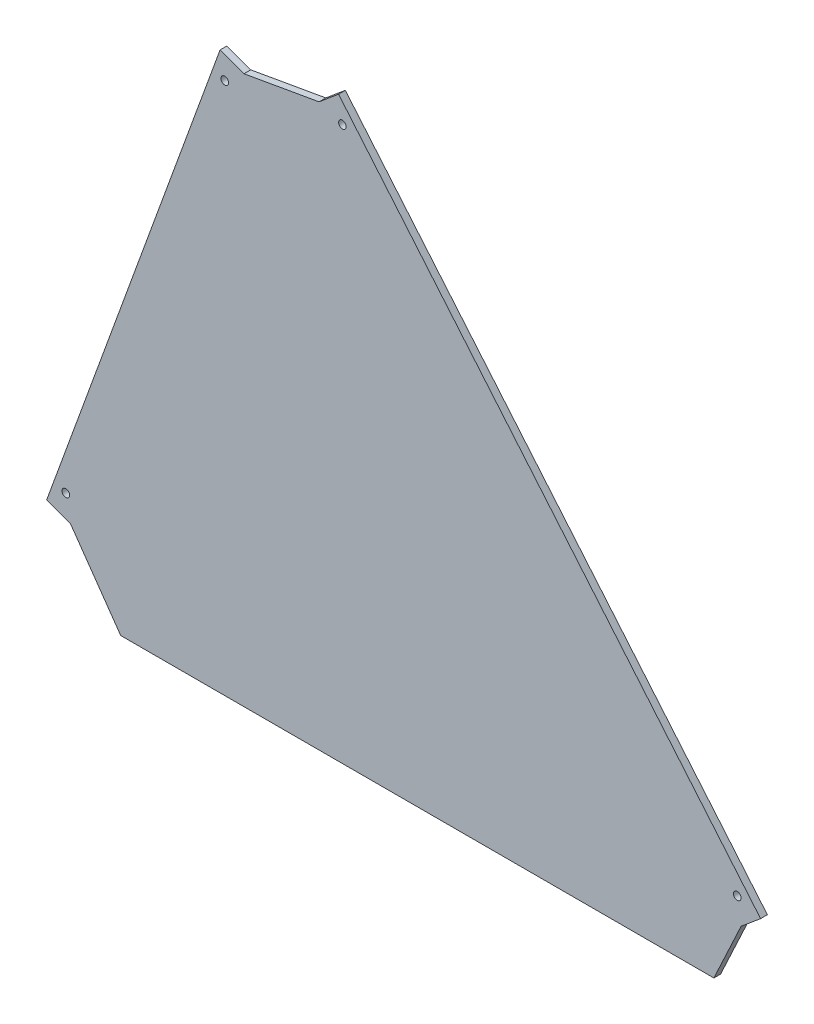
from build123d import *

# Parameters (mm, degrees)
EXTRUDE_1_DEPTH    = 4
HOLE_WIZARD_M4_1_D = 4.5


with BuildPart() as part:
    # ｽｹｯﾁ1 → ﾎﾞｽ - 押し出し1 (new body)
    with BuildSketch(Plane.XY):
        Polygon((162.040656836, 331.259045811), (411.074557564, 34.47199994), (395, 0), (45, 0), (15.39090645, 42.286167935), (117.724307951, 323.444877815), align=None)
        Polygon((117.724307951, 323.444877815), (103.628918639, 328.575179965), (1.295517138, 47.416470085), (15.39090645, 42.286167935), align=None)
        Polygon((173.531323483, 340.900859956), (422.565224211, 44.113814086), (411.074557564, 34.47199994), (162.040656836, 331.259045811), align=None)
    extrude(amount=EXTRUDE_1_DEPTH)

    # M4 すきま穴1 (through all)
    with Locations(Plane.XY.offset(4)):
        with Locations((106.401361503, 314.263871131), (12.618463585, 56.59747677), (175.820835281, 326.504397344), (408.785045766, 48.868462552)):
            Hole(HOLE_WIZARD_M4_1_D / 2)


solid = part.part
